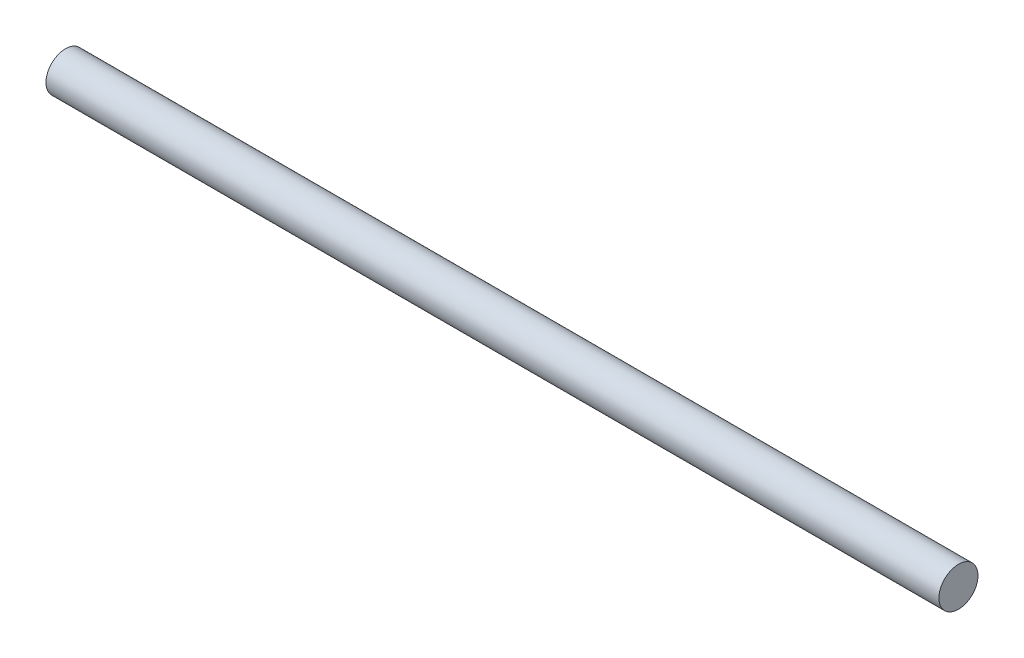
from build123d import *

# Parameters (mm, degrees)
SKETCH1_R           = 3.5
BOSS_EXTRUDE1_DEPTH = 160


with BuildPart() as part:
    # Sketch1 → Boss-Extrude1 (new body)
    with BuildSketch(Plane(origin=(0, 0, 0), x_dir=(0, 0, -1), z_dir=(1, 0, 0))):
        with Locations((-58.398216819, -31.828976652)):
            Circle(SKETCH1_R)
    extrude(amount=BOSS_EXTRUDE1_DEPTH)


solid = part.part
